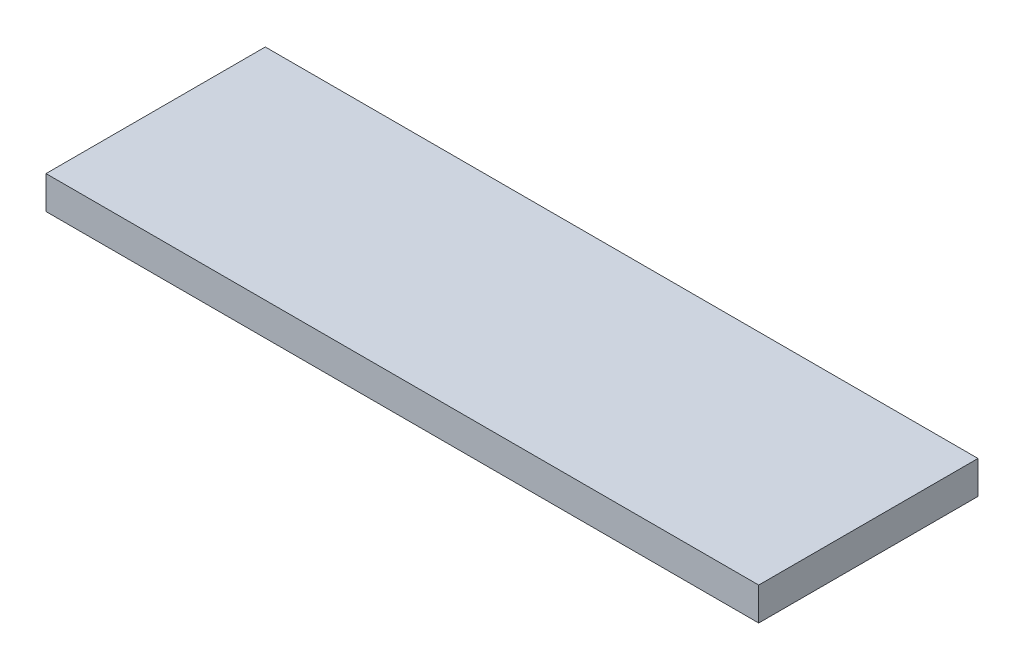
from build123d import *

# Parameters (mm, degrees)
SKIZZE1_W                       = 65
SKIZZE1_H                       = 20
AUFSATZ_LINEAR_AUSTRAGEN1_DEPTH = 3


with BuildPart() as part:
    # Skizze1 → Aufsatz-Linear austragen1 (new body)
    with BuildSketch(Plane(origin=(0, 0, 0), x_dir=(1, 0, 0), z_dir=(0, 1, 0))):
        Rectangle(SKIZZE1_W, SKIZZE1_H)
    extrude(amount=AUFSATZ_LINEAR_AUSTRAGEN1_DEPTH)


solid = part.part
